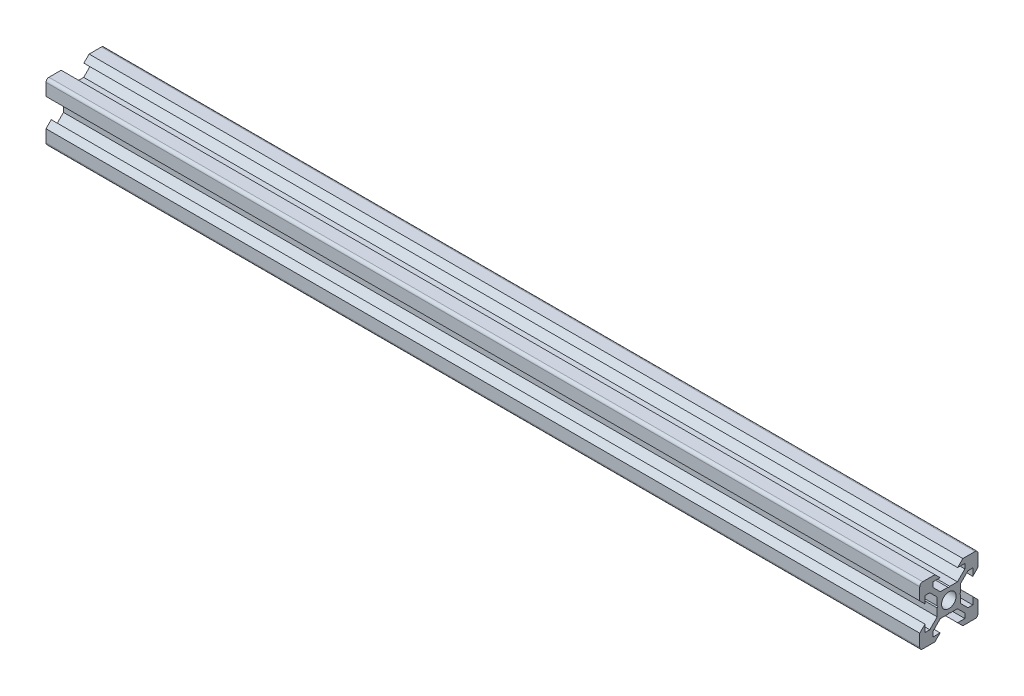
from build123d import *

# Parameters (mm, degrees)
SKETCH11_R                                  = 2.5
QUADRADO_PF20_11_PERFIL_2020_V_SLOT_1_DEPTH = 300


with BuildPart() as part:
    # Sketch11 → Quadrado PF20-11 - PERFIL 2020 V-SLOT(1) (new body)
    with BuildSketch(Plane.YZ):
        with BuildLine():
            Line((-4.8, 10), (-3, 8.2))
            Line((-3, 8.2), (-5.5, 8.2))
            Line((-5.5, 8.2), (-5.5, 6.560660172))
            Line((-5.5, 6.560660172), (-2.939339828, 4))
            Line((-2.939339828, 4), (-0.3, 4))
            Line((-0.3, 4), (0, 3.7))
            Line((0, 3.7), (0.3, 4))
            Line((0.3, 4), (2.939339828, 4))
            Line((2.939339828, 4), (5.5, 6.560660172))
            Line((5.5, 6.560660172), (5.5, 8.2))
            Line((5.5, 8.2), (3, 8.2))
            Line((3, 8.2), (4.8, 10))
            Line((4.8, 10), (9, 10))
            ThreePointArc((9, 10), (9.707106781, 9.707106781), (10, 9))
            Line((10, 9), (10, 4.8))
            Line((10, 4.8), (8.2, 3))
            Line((8.2, 3), (8.2, 5.5))
            Line((8.2, 5.5), (6.560660172, 5.5))
            Line((6.560660172, 5.5), (4, 2.939339828))
            Line((4, 2.939339828), (4, 0.3))
            Line((4, 0.3), (3.7, 0))
            Line((3.7, 0), (4, -0.3))
            Line((4, -0.3), (4, -2.939339828))
            Line((4, -2.939339828), (6.560660172, -5.5))
            Line((6.560660172, -5.5), (8.2, -5.5))
            Line((8.2, -5.5), (8.2, -3))
            Line((8.2, -3), (10, -4.8))
            Line((10, -4.8), (10, -9))
            ThreePointArc((10, -9), (9.707106781, -9.707106781), (9, -10))
            Line((9, -10), (4.8, -10))
            Line((4.8, -10), (3, -8.2))
            Line((3, -8.2), (5.5, -8.2))
            Line((5.5, -8.2), (5.5, -6.560660172))
            Line((5.5, -6.560660172), (2.939339828, -4))
            Line((2.939339828, -4), (0.3, -4))
            Line((0.3, -4), (0, -3.7))
            Line((0, -3.7), (-0.3, -4))
            Line((-0.3, -4), (-2.939339828, -4))
            Line((-2.939339828, -4), (-5.5, -6.560660172))
            Line((-5.5, -6.560660172), (-5.5, -8.2))
            Line((-5.5, -8.2), (-3, -8.2))
            Line((-3, -8.2), (-4.8, -10))
            Line((-4.8, -10), (-9, -10))
            ThreePointArc((-9, -10), (-9.707106781, -9.707106781), (-10, -9))
            Line((-10, -9), (-10, -4.8))
            Line((-10, -4.8), (-8.2, -3))
            Line((-8.2, -3), (-8.2, -5.5))
            Line((-8.2, -5.5), (-6.560660172, -5.5))
            Line((-6.560660172, -5.5), (-4, -2.939339828))
            Line((-4, -2.939339828), (-4, -0.3))
            Line((-4, -0.3), (-3.7, 0))
            Line((-3.7, 0), (-4, 0.3))
            Line((-4, 0.3), (-4, 2.939339828))
            Line((-4, 2.939339828), (-6.560660172, 5.5))
            Line((-6.560660172, 5.5), (-8.2, 5.5))
            Line((-8.2, 5.5), (-8.2, 3))
            Line((-8.2, 3), (-10, 4.8))
            Line((-10, 4.8), (-10, 9))
            ThreePointArc((-10, 9), (-9.707106781, 9.707106781), (-9, 10))
            Line((-9, 10), (-4.8, 10))
        make_face()
        Circle(SKETCH11_R, mode=Mode.SUBTRACT)
    extrude(amount=QUADRADO_PF20_11_PERFIL_2020_V_SLOT_1_DEPTH)


solid = part.part
